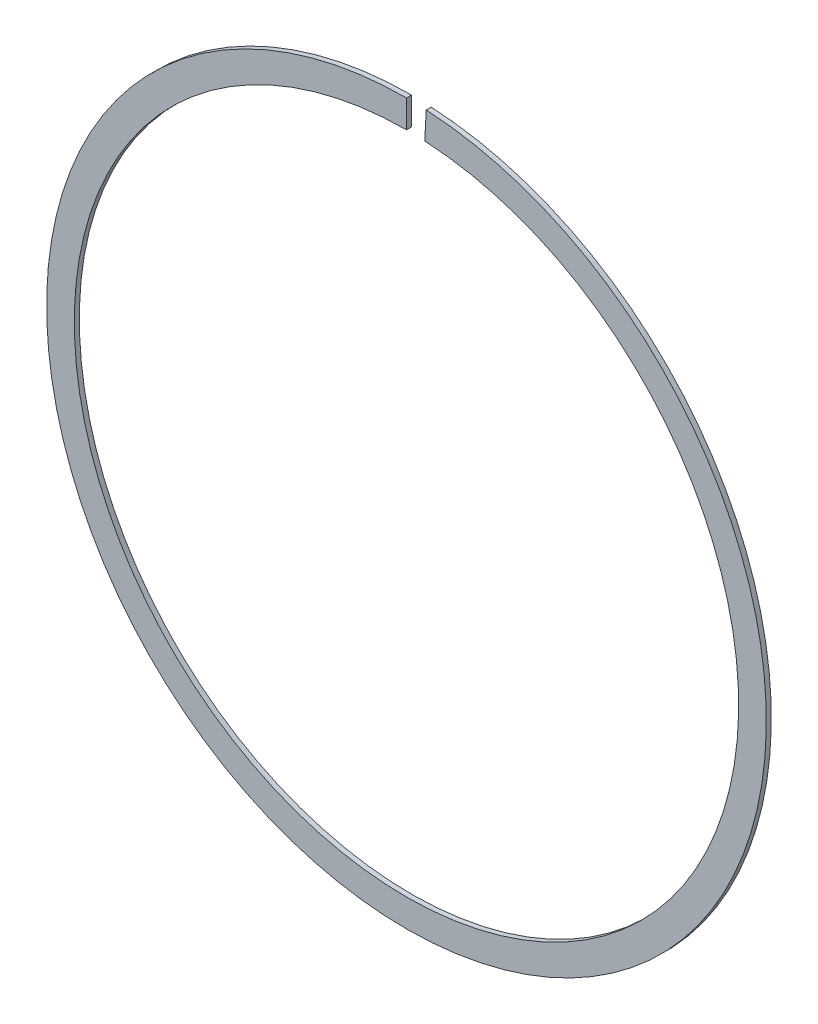
from build123d import *

# Parameters (mm, degrees)
SKETCH6_W = 0.45
SKETCH6_H = 2.5


with BuildPart() as part:
    # Sweep3: sweep along a path in Sketch5
    with BuildLine(Plane.XY) as sweep3_path:
        ThreePointArc((0, 32.5), (-0.893277901, -32.487721597), (1.785880847, 32.450895667))
    # Sketch6 → Sweep3 (sweep)
    with BuildSketch(Plane(origin=(0, 0, 0), x_dir=(0, 0, -1), z_dir=(1, 0, 0))):
        with Locations((0, 31.25)):
            Rectangle(SKETCH6_W, SKETCH6_H)
    sweep(path=sweep3_path.line)


solid = part.part
